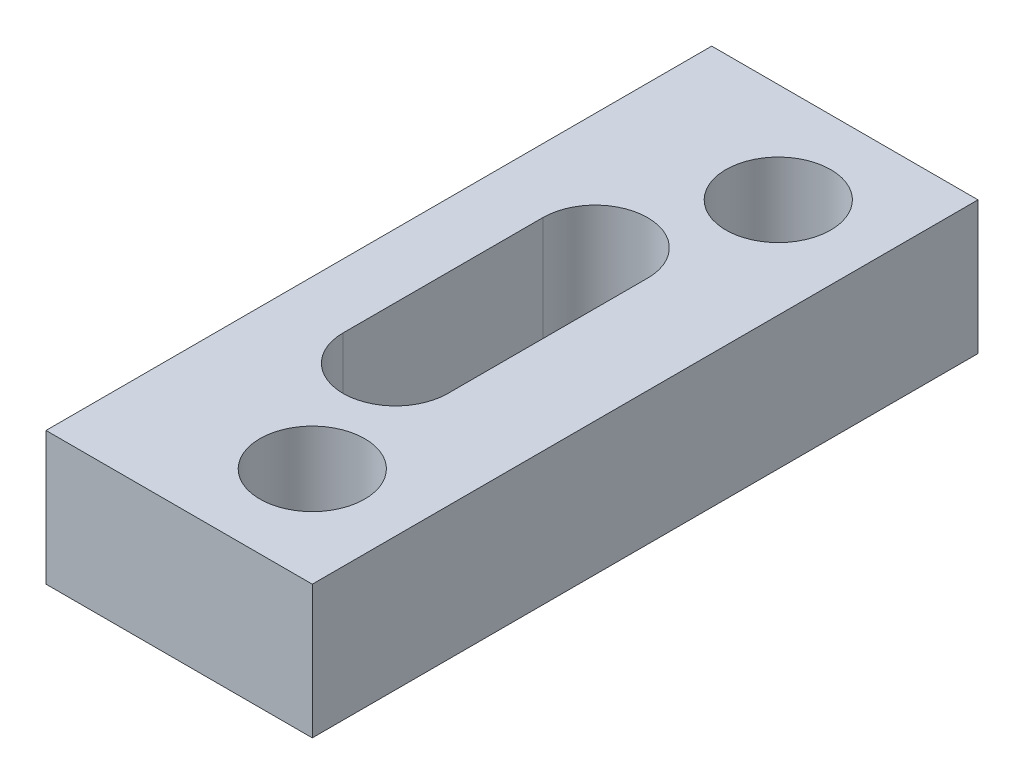
from build123d import *

# Parameters (mm, degrees)
SKETCH1_W           = 8
SKETCH1_H           = 20
SKETCH1_R           = 1.575
BOSS_EXTRUDE1_DEPTH = 4


with BuildPart() as part:
    # Sketch1 → Boss-Extrude1 (new body)
    with BuildSketch(Plane(origin=(0, 0, 0), x_dir=(1, 0, 0), z_dir=(0, 1, 0))):
        with Locations((4, 10)):
            Rectangle(SKETCH1_W, SKETCH1_H)
        with Locations((5, 17)):
            Circle(SKETCH1_R, mode=Mode.SUBTRACT)
        with Locations((5, 3)):
            Circle(SKETCH1_R, mode=Mode.SUBTRACT)
        with BuildLine():
            Line((1.925, 7), (1.925, 13))
            ThreePointArc((1.925, 13), (3.5, 14.575), (5.075, 13))
            Line((5.075, 13), (5.075, 7))
            ThreePointArc((5.075, 7), (3.5, 5.425), (1.925, 7))
        make_face(mode=Mode.SUBTRACT)
    extrude(amount=-BOSS_EXTRUDE1_DEPTH)


solid = part.part
